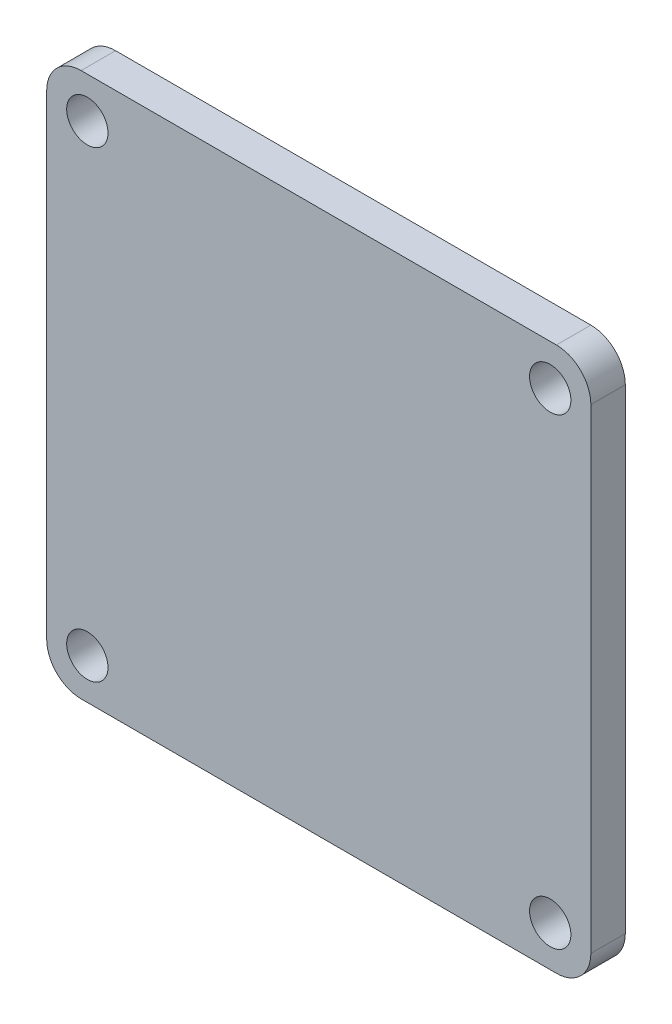
from build123d import *

# Parameters (mm, degrees)
SKETCH1_W           = 39.5
SKETCH1_H           = 39.5
BOSS_EXTRUDE1_DEPTH = 2.5
SKETCH2_R           = 1.5
CUT_EXTRUDE1_DEPTH  = 2.5
FILLET1_R           = 2.5


with BuildPart() as part:
    # Sketch1 → Boss-Extrude1 (new body)
    with BuildSketch(Plane.XY):
        with Locations((19.75, 19.75)):
            Rectangle(SKETCH1_W, SKETCH1_H)
    extrude(amount=BOSS_EXTRUDE1_DEPTH)

    # Sketch2 → Cut-Extrude1 (cut)
    with BuildSketch(Plane.XY.offset(2.5)):
        with Locations((2.95, 36.55)):
            Circle(SKETCH2_R)
        with Locations((36.55, 36.55)):
            Circle(SKETCH2_R)
        with Locations((36.55, 2.95)):
            Circle(SKETCH2_R)
        with Locations((2.95, 2.95)):
            Circle(SKETCH2_R)
    extrude(amount=-CUT_EXTRUDE1_DEPTH, mode=Mode.SUBTRACT)

    # Fillet1
    fillet1_edges = [part.edges().sort_by_distance(p)[0] for p in [
        (0, 39.5, 1.25),
        (39.5, 39.5, 1.25),
        (39.5, 0, 1.25),
        (0, 0, 1.25),
    ]]
    fillet(fillet1_edges, radius=FILLET1_R)


solid = part.part
